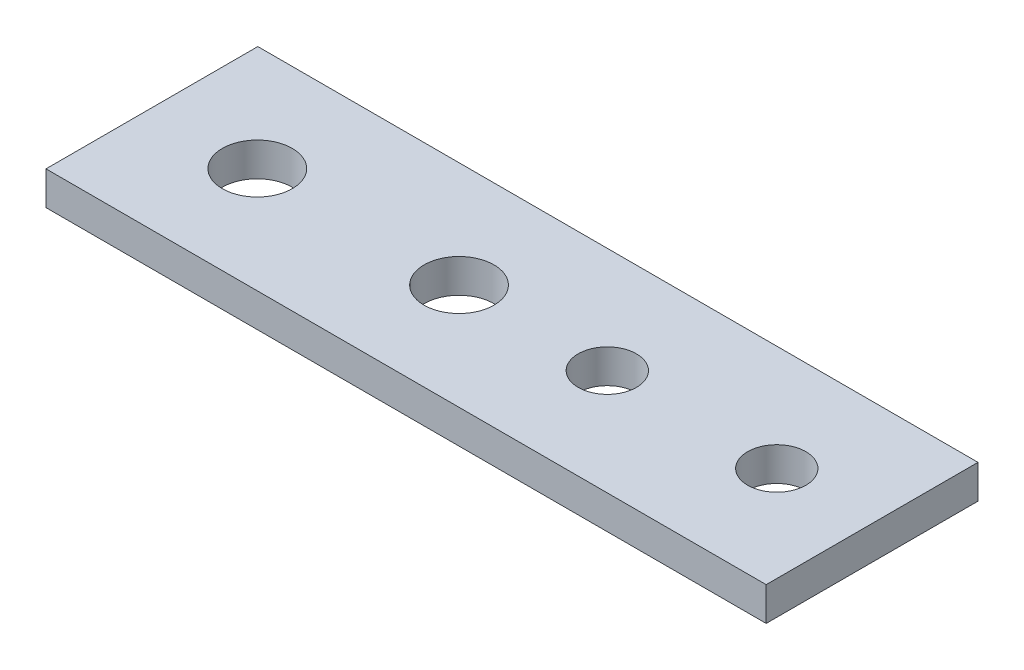
from build123d import *

# Parameters (mm, degrees)
SKETCH1_W                = 68
SKETCH1_H                = 20
BOSS_EXTRUDE1_DEPTH      = 3.175
M6_CLEARANCE_HOLE1_D     = 6.6
M6_CLEARANCE_HOLE1_DEPTH = 14
M6_CLEARANCE_HOLE1_TIP   = 1.982840043
M5_CLEARANCE_HOLE1_D     = 5.5
M5_CLEARANCE_HOLE1_DEPTH = 14
M5_CLEARANCE_HOLE1_TIP   = 1.652366702


with BuildPart() as part:
    # Sketch1 → Boss-Extrude1 (new body)
    with BuildSketch(Plane(origin=(0, 0, 0), x_dir=(1, 0, 0), z_dir=(0, 1, 0))):
        with Locations((-34, 10)):
            Rectangle(SKETCH1_W, SKETCH1_H)
    extrude(amount=BOSS_EXTRUDE1_DEPTH)

    # M6 Clearance Hole1
    with Locations(Plane(origin=(-39, 3.175, -10), x_dir=(0, 0, 1), z_dir=(0, 1, 0))):
        with Locations((0, 0), (0, -19.05)):
            Hole(M6_CLEARANCE_HOLE1_D / 2, depth=M6_CLEARANCE_HOLE1_DEPTH)
            with Locations((0, 0, -(M6_CLEARANCE_HOLE1_DEPTH + M6_CLEARANCE_HOLE1_TIP / 2))):  # 118° drill point
                Cone(0, M6_CLEARANCE_HOLE1_D / 2, M6_CLEARANCE_HOLE1_TIP, mode=Mode.SUBTRACT)

    # M5 Clearance Hole1
    with Locations(Plane(origin=(-25, 3.175, -10), x_dir=(0, 0, 1), z_dir=(0, 1, 0))):
        with Locations((0, 0), (0, 16)):
            Hole(M5_CLEARANCE_HOLE1_D / 2, depth=M5_CLEARANCE_HOLE1_DEPTH)
            with Locations((0, 0, -(M5_CLEARANCE_HOLE1_DEPTH + M5_CLEARANCE_HOLE1_TIP / 2))):  # 118° drill point
                Cone(0, M5_CLEARANCE_HOLE1_D / 2, M5_CLEARANCE_HOLE1_TIP, mode=Mode.SUBTRACT)


solid = part.part
